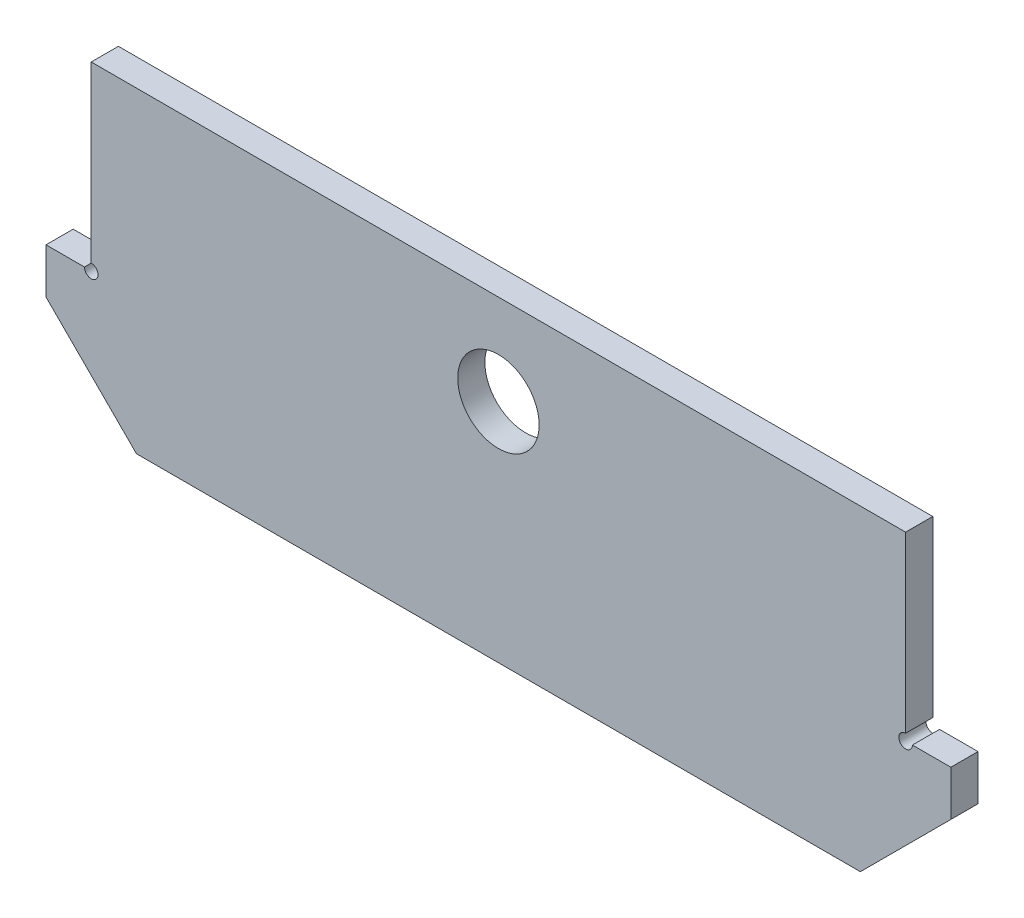
from build123d import *

# Parameters (mm, degrees)
BOSS_EXTRUDE1_START = -18.956398
BOSS_EXTRUDE1_DEPTH = 6.000001


with BuildPart() as part:
    # Sketch1 → Boss-Extrude1 (new body)
    with BuildSketch(Plane.XY.offset(BOSS_EXTRUDE1_START)):
        with BuildLine():
            Line((144.558896816, -1449.426665995), (144.558896816, -1438.426665995))
            Line((144.558896816, -1438.426665995), (54.558896816, -1438.426665995))
            Line((54.558896816, -1438.426665995), (54.558896816, -1476.926665995))
            ThreePointArc((54.558896816, -1476.926665995), (55.619556988, -1477.366005823), (56.058896816, -1478.426665995))
            ThreePointArc((56.058896816, -1478.426665995), (54.558896816, -1479.926665995), (53.058896816, -1478.426665995))
            Line((53.058896816, -1478.426665995), (44.558896816, -1478.426665995))
            Line((44.558896816, -1478.426665995), (44.558896816, -1488.426665995))
            Line((44.558896816, -1488.426665995), (64.558896816, -1508.426665995))
            Line((64.558896816, -1508.426665995), (144.558896816, -1508.426665995))
            Line((144.558896816, -1508.426665995), (144.558896816, -1467.426665995))
            ThreePointArc((144.558896816, -1467.426665995), (135.558896816, -1458.426665995), (144.558896816, -1449.426665995))
        make_face()
        with BuildLine():
            Line((234.558896816, -1438.426665995), (144.558896816, -1438.426665995))
            Line((144.558896816, -1438.426665995), (144.558896816, -1449.426665995))
            ThreePointArc((144.558896816, -1449.426665995), (150.922857847, -1452.062704964), (153.558896816, -1458.426665995))
            ThreePointArc((153.558896816, -1458.426665995), (150.922857847, -1464.790627025), (144.558896816, -1467.426665995))
            Line((144.558896816, -1467.426665995), (144.558896816, -1508.426665995))
            Line((144.558896816, -1508.426665995), (224.558896816, -1508.426665995))
            Line((224.558896816, -1508.426665995), (244.558896816, -1488.426665995))
            Line((244.558896816, -1488.426665995), (244.558896816, -1478.426665995))
            Line((244.558896816, -1478.426665995), (236.058896816, -1478.426665995))
            ThreePointArc((236.058896816, -1478.426665995), (233.498236645, -1479.487326167), (234.558896816, -1476.926665995))
            Line((234.558896816, -1476.926665995), (234.558896816, -1438.426665995))
        make_face()
    extrude(amount=BOSS_EXTRUDE1_DEPTH)


solid = part.part
